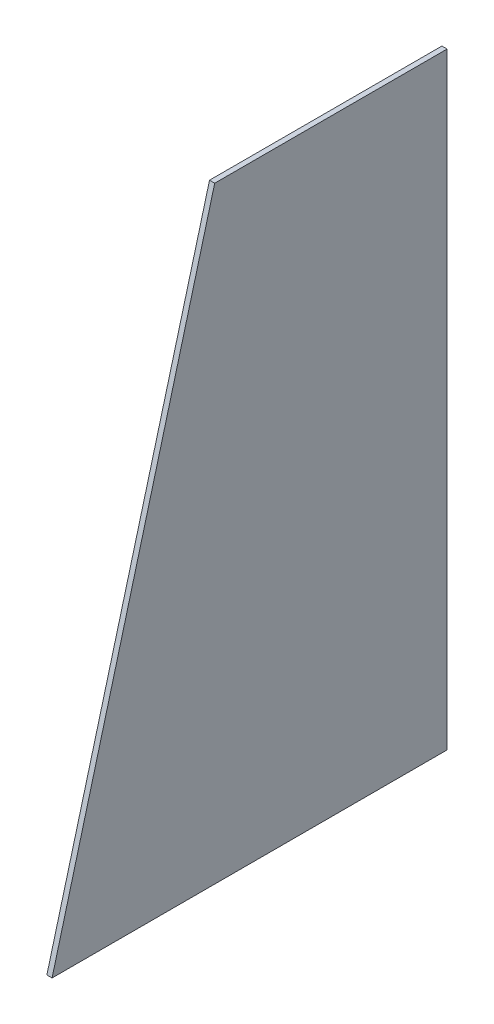
from build123d import *

# Parameters (mm, degrees)
BOSS_EXTRUDE1_DEPTH = 3


with BuildPart() as part:
    # Sketch1 → Boss-Extrude1 (new body)
    with BuildSketch(Plane(origin=(0, 0, 0), x_dir=(0, 0, -1), z_dir=(1, 0, 0))):
        Polygon((-20.144357354, 175.205305412), (111.036597544, 175.205305412), (114.036597544, 175.205305412), (114.036597544, -175.205305412), (111.036597544, -175.205305412), (-114.036597544, -175.205305412), align=None)
    extrude(amount=BOSS_EXTRUDE1_DEPTH)


solid = part.part
